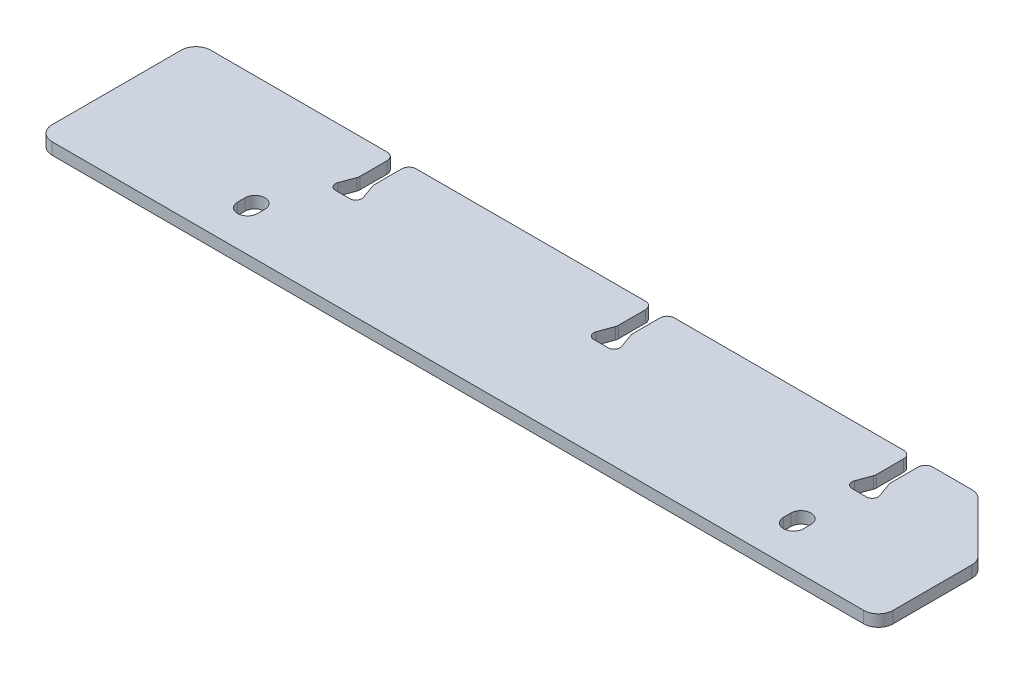
from build123d import *

# Parameters (mm, degrees)
SKETCH2_W           = 114
SKETCH2_H           = 21.5
BOSS_EXTRUDE1_DEPTH = 1.5875
CHAMFER1_SIZE       = 8
FILLET1_R           = 2
CUT_EXTRUDE1_DEPTH  = 64.755550004
LPATTERN1_COUNT     = 3
LPATTERN1_PITCH     = 35
FILLET2_R           = 1
FILLET3_R           = 1


with BuildPart() as part:
    # Sketch2 → Boss-Extrude1 (new body)
    with BuildSketch(Plane(origin=(0, 0, 0), x_dir=(1, 0, 0), z_dir=(0, 1, 0))):
        with Locations((-3, 10.75)):
            Rectangle(SKETCH2_W, SKETCH2_H)
        with BuildLine():
            Line((-38.35, 5.5), (-38.35, 6.5))
            ThreePointArc((-38.35, 6.5), (-37, 7.85), (-35.65, 6.5))
            Line((-35.65, 6.5), (-35.65, 5.5))
            ThreePointArc((-35.65, 5.5), (-37, 4.15), (-38.35, 5.5))
        make_face(mode=Mode.SUBTRACT)
        with BuildLine():
            Line((35.65, 5.5), (35.65, 6.5))
            ThreePointArc((35.65, 6.5), (37, 7.85), (38.35, 6.5))
            Line((38.35, 6.5), (38.35, 5.5))
            ThreePointArc((38.35, 5.5), (37, 4.15), (35.65, 5.5))
        make_face(mode=Mode.SUBTRACT)
    extrude(amount=BOSS_EXTRUDE1_DEPTH)

    # Chamfer1
    chamfer1_edges = [part.edges().sort_by_distance(p)[0] for p in [
        (54, 0.79375, -21.5),
    ]]
    chamfer(chamfer1_edges, length=CHAMFER1_SIZE)

    # Fillet1
    fillet1_edges = [part.edges().sort_by_distance(p)[0] for p in [
        (-60, 0.79375, -21.5),
        (-60, 0.79375, 0),
        (54, 0.79375, 0),
        (54, 0.79375, -13.5),
        (46, 0.79375, -21.5),
    ]]
    fillet(fillet1_edges, radius=FILLET1_R)

    # Sketch3 → Cut-Extrude1 (cut, through all)
    with BuildSketch(Plane(origin=(0, 0, 0), x_dir=(1, 0, 0), z_dir=(0, 1, 0))):
        with BuildLine():
            Line((-33.075, 21.5), (-31.125, 21.5))
            Line((-31.125, 21.5), (-31.125, 16.63904352))
            Line((-31.125, 16.63904352), (-30.373245903, 14.573616115))
            ThreePointArc((-30.373245903, 14.573616115), (-30.469678365, 13.841138851), (-31.125, 13.5))
            Line((-31.125, 13.5), (-33.075, 13.5))
            ThreePointArc((-33.075, 13.5), (-33.730321635, 13.841138851), (-33.826754097, 14.573616115))
            Line((-33.826754097, 14.573616115), (-33.075, 16.63904352))
            Line((-33.075, 16.63904352), (-33.075, 21.5))
        make_face()
    cut_extrude1 = extrude(amount=CUT_EXTRUDE1_DEPTH, mode=Mode.SUBTRACT)

    # LPattern1: Cut-Extrude1 ×3
    with Locations(*[(i * LPATTERN1_PITCH, 0, 0) for i in range(1, LPATTERN1_COUNT)]):
        add(cut_extrude1, mode=Mode.SUBTRACT)

    # Fillet2
    fillet2_edges = [part.edges().sort_by_distance(p)[0] for p in [
        (38.875, 0.79375, -21.5),
        (1.925, 0.79375, -21.5),
        (3.875, 0.79375, -21.5),
        (-31.125, 0.79375, -21.5),
        (36.925, 0.79375, -21.5),
        (-33.075, 0.79375, -21.5),
    ]]
    fillet(fillet2_edges, radius=FILLET2_R)

    # Fillet3
    fillet3_edges = [part.edges().sort_by_distance(p)[0] for p in [
        (36.925, 0.79375, -16.63904352),
        (38.875, 0.79375, -16.63904352),
        (1.925, 0.79375, -16.63904352),
        (3.875, 0.79375, -16.63904352),
        (-31.125, 0.79375, -16.63904352),
        (-33.075, 0.79375, -16.63904352),
    ]]
    fillet(fillet3_edges, radius=FILLET3_R)


solid = part.part
